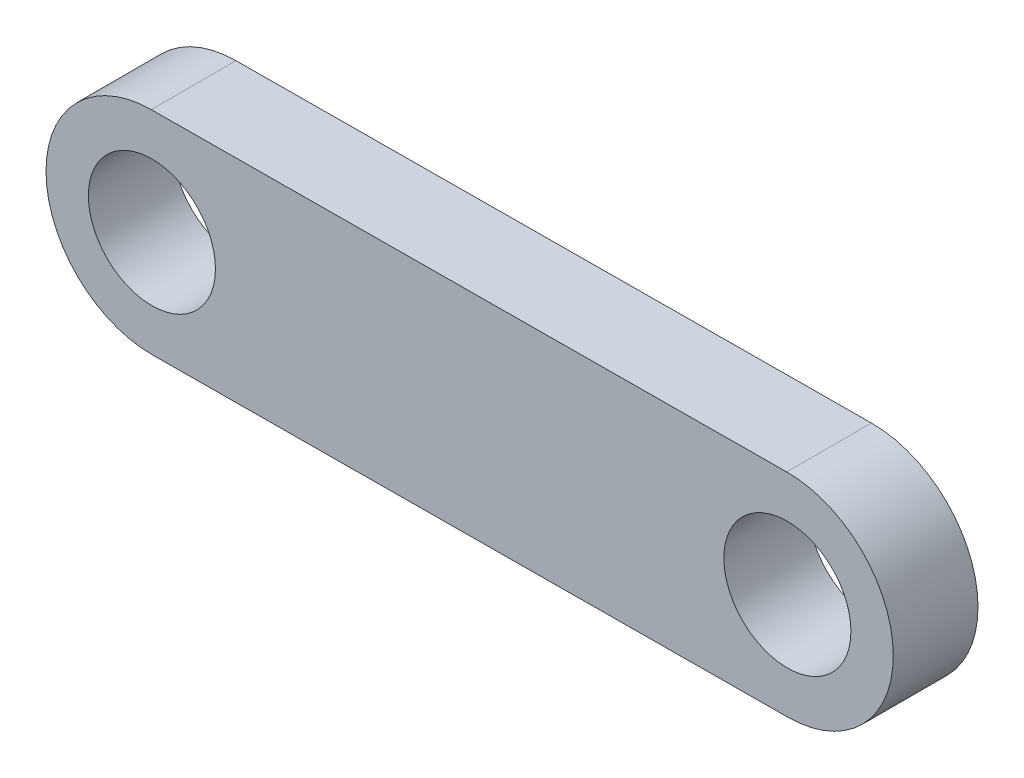
from build123d import *

# Parameters (mm, degrees)
SKETCH1_R           = 1.5
BOSS_EXTRUDE2_DEPTH = 2


with BuildPart() as part:
    # Sketch1 → Boss-Extrude2 (new body)
    with BuildSketch(Plane.XY):
        with BuildLine():
            Line((-0.015603059, 2.499951308), (14.984396941, 2.593571487))
            ThreePointArc((14.984396941, 2.593571487), (17.499951308, 0.109223238), (15.015603059, -2.406331129))
            Line((15.015603059, -2.406331129), (0.015603059, -2.499951308))
            ThreePointArc((0.015603059, -2.499951308), (-2.499951308, -0.015603059), (-0.015603059, 2.499951308))
        make_face()
        Circle(SKETCH1_R, mode=Mode.SUBTRACT)
        with Locations((15, 0.093620179)):
            Circle(SKETCH1_R, mode=Mode.SUBTRACT)
    extrude(amount=BOSS_EXTRUDE2_DEPTH)


solid = part.part
